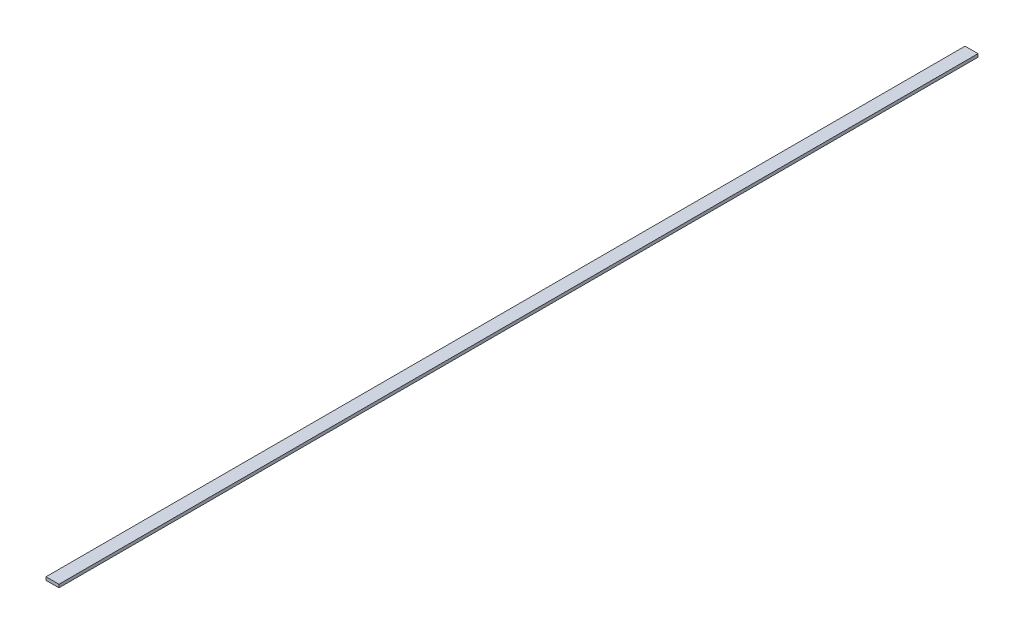
from build123d import *

# Parameters (mm, degrees)
CROQUIS1_W              = 6.2
CROQUIS1_H              = 440
SALIENTE_EXTRUIR1_DEPTH = 1.5


with BuildPart() as part:
    # Croquis1 → Saliente-Extruir1 (new body)
    with BuildSketch(Plane(origin=(0, 0, 0), x_dir=(1, 0, 0), z_dir=(0, 1, 0))):
        with Locations((3.1, 220)):
            Rectangle(CROQUIS1_W, CROQUIS1_H)
    extrude(amount=SALIENTE_EXTRUIR1_DEPTH)


solid = part.part
